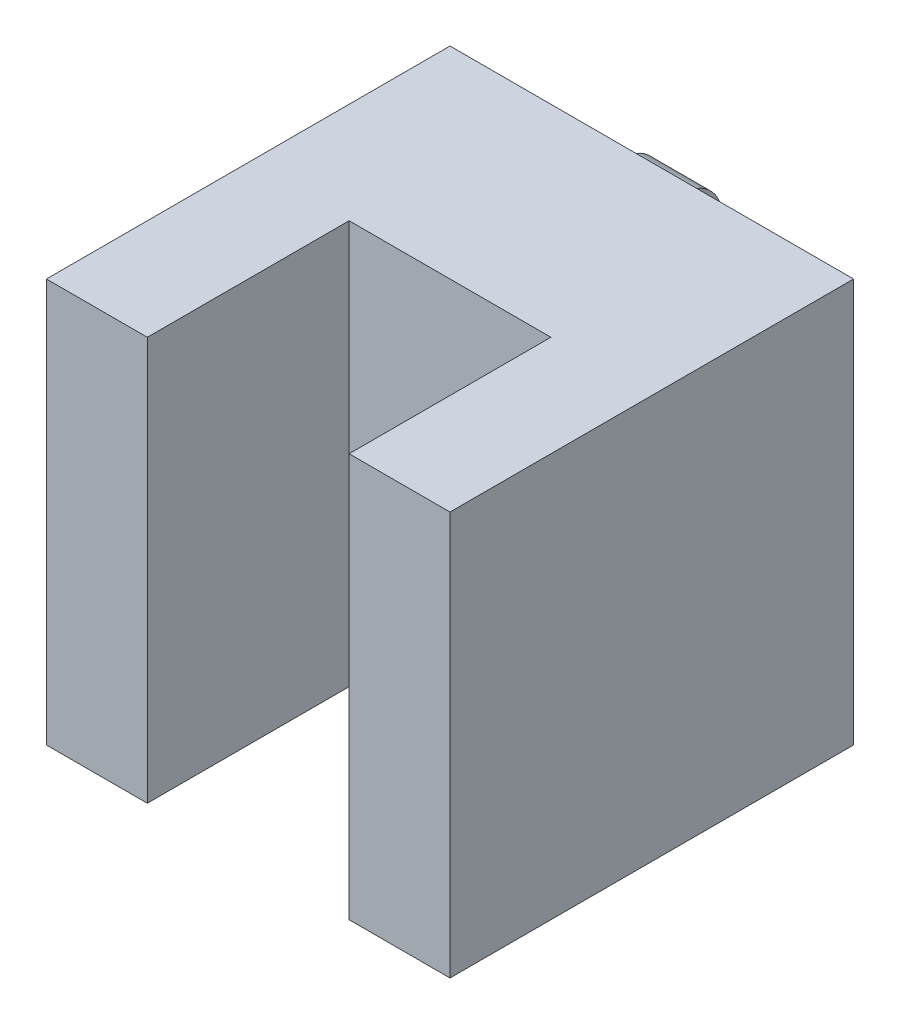
from build123d import *

# Parameters (mm, degrees)
BOSS_EXTRUDE1_DEPTH      = 20
BOSS_EXTRUDE2_DEPTH      = 1.5
BOSS_EXTRUDE2_DEPTH_BACK = 1.5


with BuildPart() as part:
    # Sketch1 → Boss-Extrude1 (new body)
    with BuildSketch(Plane(origin=(0, 0, 0), x_dir=(1, 0, 0), z_dir=(0, 1, 0))):
        Polygon((0, 0), (0, 10), (10, 10), (10, 0), (15, 0), (15, 20), (-5, 20), (-5, 0), align=None)
    extrude(amount=BOSS_EXTRUDE1_DEPTH)

    # Sketch3 → Boss-Extrude2 (add, two sides)
    with BuildSketch(Plane(origin=(5, 0, 0), x_dir=(0, 0, -1), z_dir=(1, 0, 0))) as boss_extrude2_sk:
        with BuildLine():
            Line((20, 18.912744364), (20, 19.412744364))
            ThreePointArc((20, 19.412744364), (22, 17.412744364), (20, 15.412744364))
            Line((20, 15.412744364), (20, 15.912744364))
            ThreePointArc((20, 15.912744364), (21.5, 17.412744364), (20, 18.912744364))
        make_face()
    extrude(amount=BOSS_EXTRUDE2_DEPTH)
    extrude(boss_extrude2_sk.sketch, amount=-BOSS_EXTRUDE2_DEPTH_BACK)


solid = part.part
